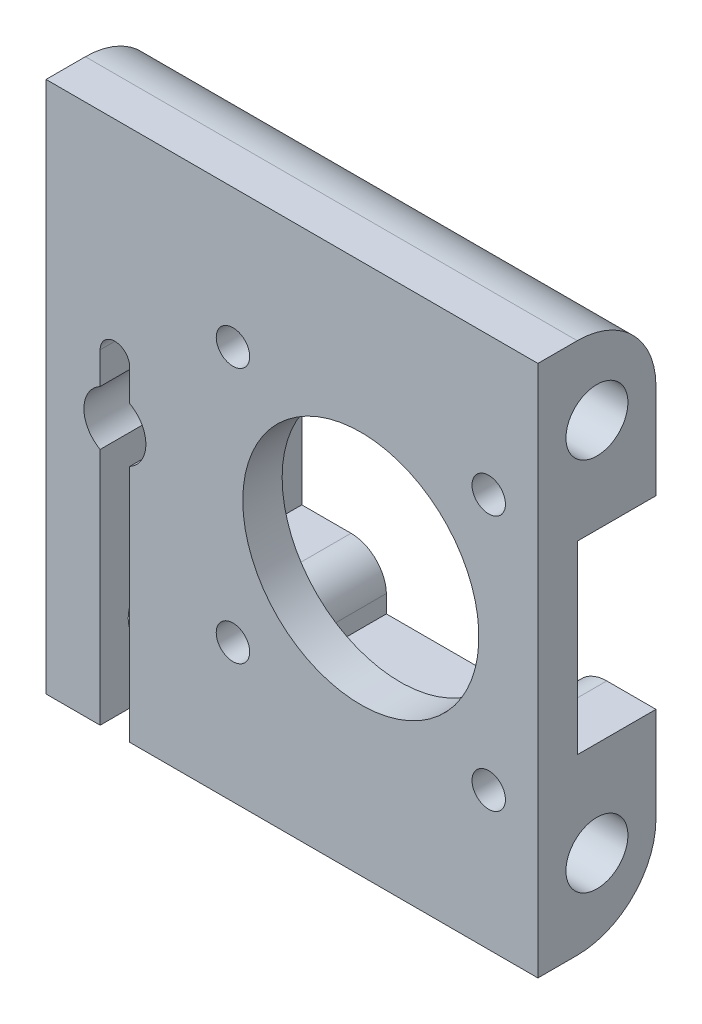
from build123d import *

# Parameters (mm, degrees)
SKETCH1_W           = 50
SKETCH1_H           = 54.105
BOSS_EXTRUDE1_DEPTH = 12
SKETCH2_R           = 3.15
CUT_EXTRUDE1_DEPTH  = 51
FILLET1_R           = 8
SKETCH3_R           = 12
SKETCH3_R_2         = 1.7
CUT_EXTRUDE2_DEPTH  = 13
CUT_EXTRUDE4_DEPTH  = 8


with BuildPart() as part:
    # Sketch1 → Boss-Extrude1 (new body)
    with BuildSketch(Plane.XY):
        with Locations((25, 27.0525)):
            Rectangle(SKETCH1_W, SKETCH1_H)
    extrude(amount=BOSS_EXTRUDE1_DEPTH)

    # Sketch2 → Cut-Extrude1 (cut, through all)
    with BuildSketch(Plane(origin=(0, 0, 0), x_dir=(0, 0, -1), z_dir=(1, 0, 0))):
        with Locations((-6, 46.105)):
            Circle(SKETCH2_R)
        with Locations((-6, 8)):
            Circle(SKETCH2_R)
    extrude(amount=CUT_EXTRUDE1_DEPTH, mode=Mode.SUBTRACT)

    # Fillet1
    fillet1_edges = [part.edges().sort_by_distance(p)[0] for p in [
        (25, 54.105, 0),
        (25, 0, 0),
    ]]
    fillet(fillet1_edges, radius=FILLET1_R)

    # Sketch3 → Cut-Extrude2 (cut, through all)
    with BuildSketch(Plane(origin=(0, 0, 0), x_dir=(-1, 0, 0), z_dir=(0, 0, -1))):
        with Locations((-32, 27.0525)):
            Circle(SKETCH3_R)
        with Locations((-19, 40.0525)):
            Circle(SKETCH3_R_2)
        with Locations((-19, 14.0525)):
            Circle(SKETCH3_R_2)
        with Locations((-45, 14.0525)):
            Circle(SKETCH3_R_2)
        with Locations((-45, 40.0525)):
            Circle(SKETCH3_R_2)
        with BuildLine():
            Line((-8.5, 0), (-8.5, 24.282572203))
            ThreePointArc((-8.5, 24.282572203), (-10.15, 27.0525), (-8.5, 29.822427797))
            Line((-8.5, 29.822427797), (-8.5, 33.0525))
            ThreePointArc((-8.5, 33.0525), (-7, 34.5525), (-5.5, 33.0525))
            Line((-5.5, 33.0525), (-5.5, 29.822427797))
            ThreePointArc((-5.5, 29.822427797), (-3.85, 27.0525), (-5.5, 24.282572203))
            Line((-5.5, 24.282572203), (-5.5, 0))
            Line((-5.5, 0), (-8.5, 0))
        make_face()
    extrude(amount=-CUT_EXTRUDE2_DEPTH, mode=Mode.SUBTRACT)

    # Sketch5 → Cut-Extrude4 (cut)
    with BuildSketch(Plane(origin=(0, 0, 0), x_dir=(-1, 0, 0), z_dir=(0, 0, -1))):
        with BuildLine():
            Line((-19, 17.6525), (-14, 17.6525))
            Line((-14, 17.6525), (-14, 36.4525))
            Line((-14, 36.4525), (-19, 36.4525))
            ThreePointArc((-19, 36.4525), (-21.510876341, 37.472674425), (-22.598679445, 39.955))
            Line((-22.598679445, 39.955), (-22.598679445, 41.7525))
            Line((-22.598679445, 41.7525), (-41.401320555, 41.7525))
            Line((-41.401320555, 41.7525), (-41.401320555, 39.955))
            ThreePointArc((-41.401320555, 39.955), (-42.489123659, 37.472674425), (-45, 36.4525))
            Line((-45, 36.4525), (-50, 36.4525))
            Line((-50, 36.4525), (-50, 17.6525))
            Line((-50, 17.6525), (-45, 17.6525))
            ThreePointArc((-45, 17.6525), (-42.489123659, 16.632325575), (-41.401320555, 14.15))
            Line((-41.401320555, 14.15), (-41.401320555, 12.3525))
            Line((-41.401320555, 12.3525), (-22.598679445, 12.3525))
            Line((-22.598679445, 12.3525), (-22.598679445, 14.15))
            ThreePointArc((-22.598679445, 14.15), (-21.510876341, 16.632325575), (-19, 17.6525))
        make_face()
    extrude(amount=-CUT_EXTRUDE4_DEPTH, mode=Mode.SUBTRACT)


solid = part.part
